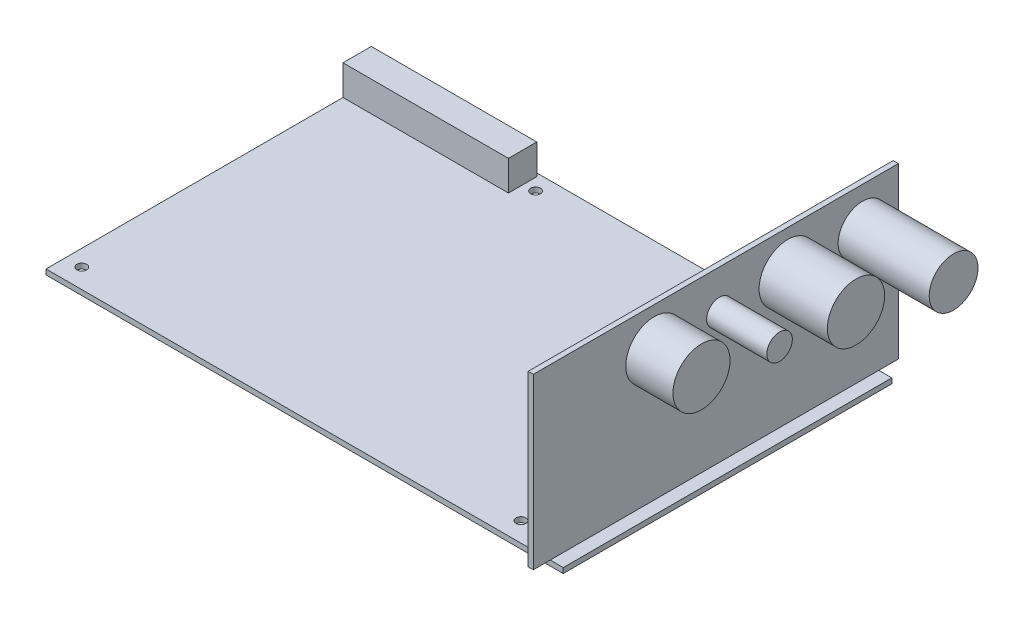
from build123d import *

# Parameters (mm, degrees)
SKETCH1_W                = 159
SKETCH1_H                = 101
SKETCH1_R                = 1.5
MAIN_BOARD_DEPTH         = 1.6
SKETCH2_W                = 50.87
SKETCH2_H                = 8.71
CONNECTOR_DEPTH          = 9.24
SKETCH3_W                = 1.6
SKETCH3_H                = 112.2
CONNECTOR_BOARD_DEPTH    = 52.04
SKETCH4_R                = 7.5
CAN_CONNECTOR_DEPTH      = 28
SKETCH5_R                = 8.8
MAIN_LV_CONNECTOR_DEPTH  = 21
SKETCH6_R                = 3.93
SERIAL_CONNECTOR_DEPTH   = 18.5
SKETCH7_R                = 8.775
FEEDBACK_CONNECTOR_DEPTH = 14.5


with BuildPart() as part:
    # Sketch1 → Main Board (new body)
    with BuildSketch(Plane(origin=(0, 0, 0), x_dir=(1, 0, 0), z_dir=(0, 1, 0))):
        Rectangle(SKETCH1_W, SKETCH1_H)
        with Locations((-25, 45.5)):
            Circle(SKETCH1_R, mode=Mode.SUBTRACT)
        with Locations((30.5, 40.5)):
            Circle(SKETCH1_R, mode=Mode.SUBTRACT)
        with Locations((-74.5, -44.5)):
            Circle(SKETCH1_R, mode=Mode.SUBTRACT)
        with Locations((60.5, -44.5)):
            Circle(SKETCH1_R, mode=Mode.SUBTRACT)
    extrude(amount=MAIN_BOARD_DEPTH)

    # Sketch2 → Connector (add)
    with BuildSketch(Plane(origin=(0, 1.6, 0), x_dir=(1, 0, 0), z_dir=(0, 1, 0))):
        with Locations((-54.065, 45.145)):
            Rectangle(SKETCH2_W, SKETCH2_H)
    extrude(amount=CONNECTOR_DEPTH)

    # Sketch3 → Connector Board (add)
    with BuildSketch(Plane(origin=(0, 1.6, 0), x_dir=(1, 0, 0), z_dir=(0, 1, 0))):
        with Locations((74.7, 0.4)):
            Rectangle(SKETCH3_W, SKETCH3_H)
    extrude(amount=CONNECTOR_BOARD_DEPTH)

    # Sketch4 → CAN Connector (add)
    with BuildSketch(Plane(origin=(75.5, 0, 0), x_dir=(0, 0, -1), z_dir=(1, 0, 0))):
        with Locations((45.5, 41.64)):
            Circle(SKETCH4_R)
    extrude(amount=CAN_CONNECTOR_DEPTH)

    # Sketch5 → Main LV Connector (add)
    with BuildSketch(Plane(origin=(75.5, 0, 0), x_dir=(0, 0, -1), z_dir=(1, 0, 0))):
        with Locations((22.5, 41.64)):
            Circle(SKETCH5_R)
    extrude(amount=MAIN_LV_CONNECTOR_DEPTH)

    # Sketch6 → Serial Connector (add)
    with BuildSketch(Plane(origin=(75.5, 0, 0), x_dir=(0, 0, -1), z_dir=(1, 0, 0))):
        with Locations((1.5, 41.64)):
            Circle(SKETCH6_R)
    extrude(amount=SERIAL_CONNECTOR_DEPTH)

    # Sketch7 → Feedback Connector (add)
    with BuildSketch(Plane(origin=(75.5, 0, 0), x_dir=(0, 0, -1), z_dir=(1, 0, 0))):
        with Locations((-18.5, 41.64)):
            Circle(SKETCH7_R)
    extrude(amount=FEEDBACK_CONNECTOR_DEPTH)


solid = part.part
